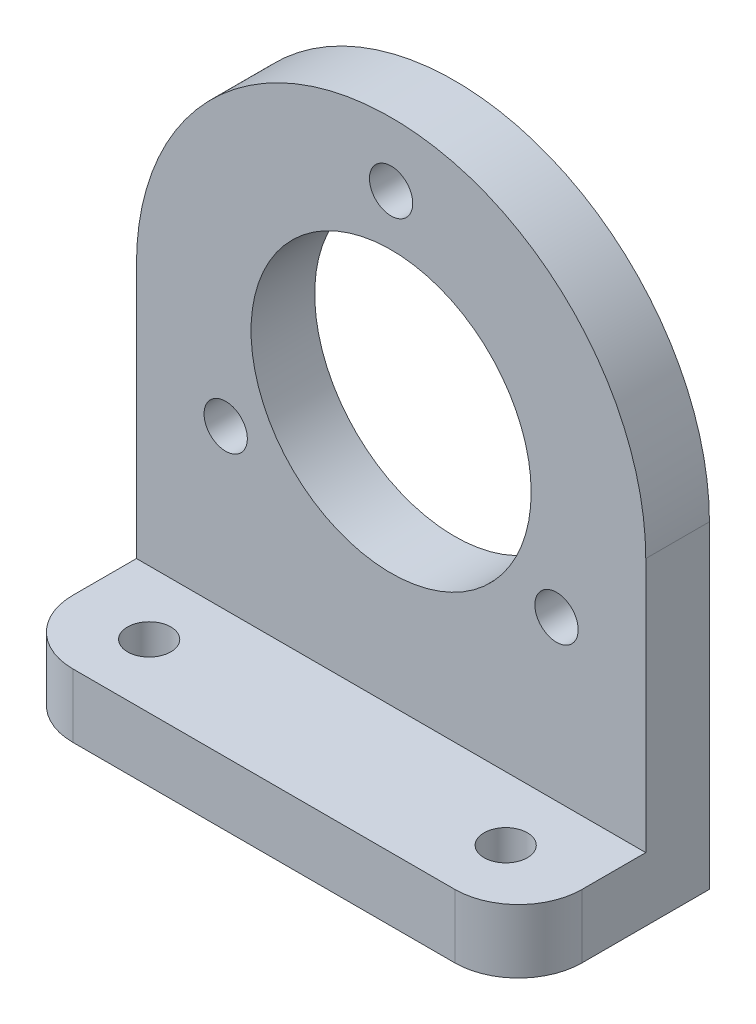
from build123d import *

# Parameters (mm, degrees)
SKETCH1_R            = 11
BOSS_EXTRUDE1_DEPTH  = 5
M3_CLEARANCE_HOLE1_D = 3.4
CIRPATTERN1_COUNT    = 3
SKETCH5_W            = 40
SKETCH5_H            = 5
BOSS_EXTRUDE2_DEPTH  = 15
M3_CLEARANCE_HOLE3_D = 3.4
FILLET1_R            = 5


with BuildPart() as part:
    # Sketch1 → Boss-Extrude1 (new body)
    with BuildSketch(Plane.XY):
        with BuildLine():
            Line((-20, -4.3e-08), (-20, -20))
            Line((-20, -20), (20, -20))
            Line((20, -20), (20, 0))
            ThreePointArc((20, 0), (-2.2e-08, 20), (-20, -4.3e-08))
        make_face()
        Circle(SKETCH1_R, mode=Mode.SUBTRACT)
    extrude(amount=BOSS_EXTRUDE1_DEPTH)

    # M3 Clearance Hole1 (through all)
    with Locations(Plane(origin=(0, 15, 5), x_dir=(1, 0, 0), z_dir=(0, 0, 1))):
        with Locations((0, 0)):
            m3_clearance_hole1 = Hole(M3_CLEARANCE_HOLE1_D / 2)

    # CirPattern1: M3 Clearance Hole1 ×3 about axis
    cirpattern1_axis = Axis((0, 0, 0), (0, 0, 1))
    for i in range(1, CIRPATTERN1_COUNT):
        add(m3_clearance_hole1.rotate(cirpattern1_axis, i * 360 / CIRPATTERN1_COUNT), mode=Mode.SUBTRACT)

    # Sketch5 → Boss-Extrude2 (add)
    with BuildSketch(Plane.XY):
        with Locations((0, -22.5)):
            Rectangle(SKETCH5_W, SKETCH5_H)
    extrude(amount=BOSS_EXTRUDE2_DEPTH)

    # M3 Clearance Hole3 (through all)
    with Locations(Plane(origin=(-14, -20, 10), x_dir=(0, 0, 1), z_dir=(0, 1, 0))):
        with Locations((0, 0), (0, 28)):
            Hole(M3_CLEARANCE_HOLE3_D / 2)

    # Fillet1
    fillet1_edges = [part.edges().sort_by_distance(p)[0] for p in [
        (-20, -22.5, 15),
        (20, -22.5, 15),
    ]]
    fillet(fillet1_edges, radius=FILLET1_R)


solid = part.part
